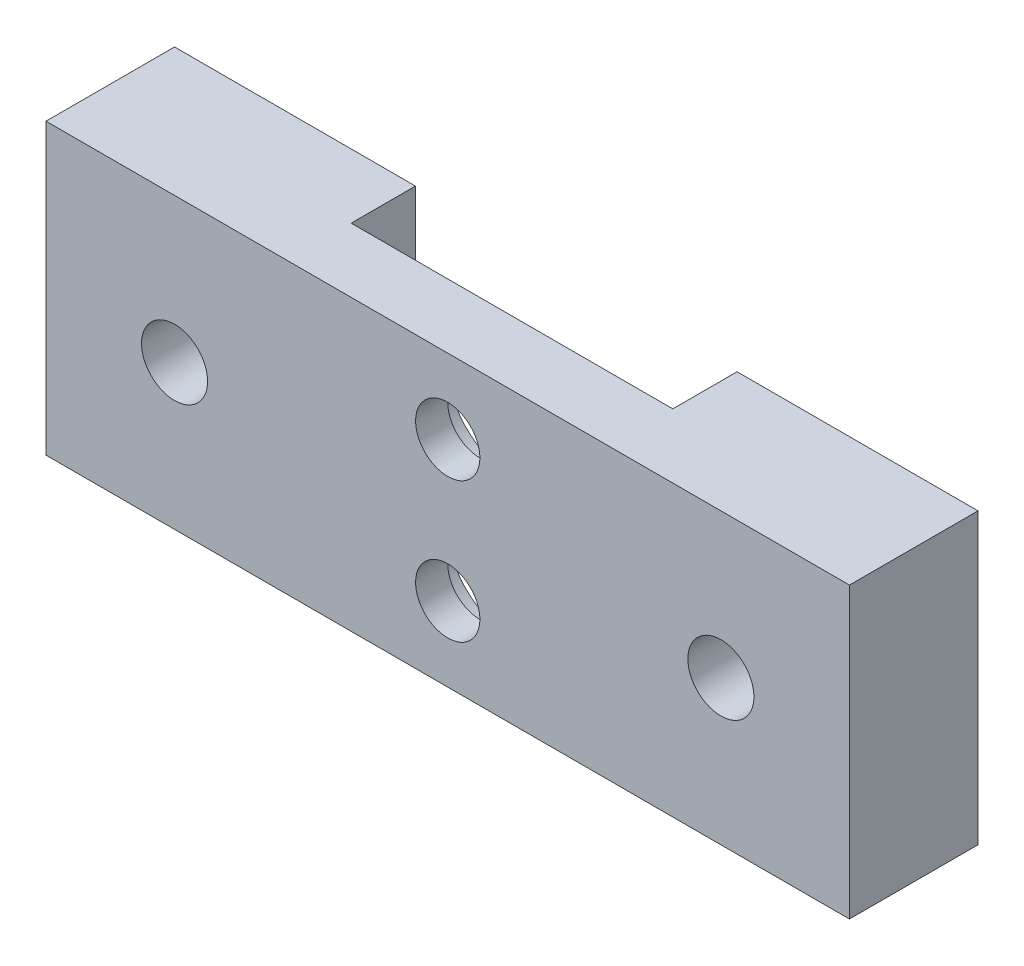
from build123d import *

# Parameters (mm, degrees)
BOSS_EXTRUDE1_DEPTH      = 28.575
F_5_16_18_TAPPED_HOLE1_D = 6.5278
HOLE4_D                  = 6.35
HOLE4_DEPTH              = 6.35
HOLE4_CBORE_D            = 12.7
HOLE4_CBORE_DEPTH        = 3.175
HOLE4_TIP                = 1.907732465


with BuildPart() as part:
    # Sketch1 → Boss-Extrude1 (new body)
    with BuildSketch(Plane(origin=(0, 0, 0), x_dir=(1, 0, 0), z_dir=(0, 1, 0))):
        Polygon((-39.6875, 0), (39.6875, 0), (39.6875, 12.7), (15.8877, 12.7), (15.8877, 6.35), (-15.8877, 6.35), (-15.8877, 12.7), (-39.6875, 12.7), align=None)
    extrude(amount=BOSS_EXTRUDE1_DEPTH)

    # 5/16-18 Tapped Hole1 (through all)
    with Locations(Plane(origin=(0, 0, -12.7), x_dir=(-1, 0, 0), z_dir=(0, 0, -1))):
        with Locations((26.9875, 14.2875), (-26.9875, 14.2875)):
            Hole(F_5_16_18_TAPPED_HOLE1_D / 2)

    # Hole4
    with Locations(Plane(origin=(0, 0, -6.35), x_dir=(-1, 0, 0), z_dir=(0, 0, -1))):
        with Locations((0, 21.1963), (0, 7.3787)):
            CounterBoreHole(HOLE4_D / 2, HOLE4_CBORE_D / 2, HOLE4_CBORE_DEPTH, depth=HOLE4_DEPTH)
            with Locations((0, 0, -(HOLE4_DEPTH + HOLE4_TIP / 2))):  # 118° drill point
                Cone(0, HOLE4_D / 2, HOLE4_TIP, mode=Mode.SUBTRACT)


solid = part.part
